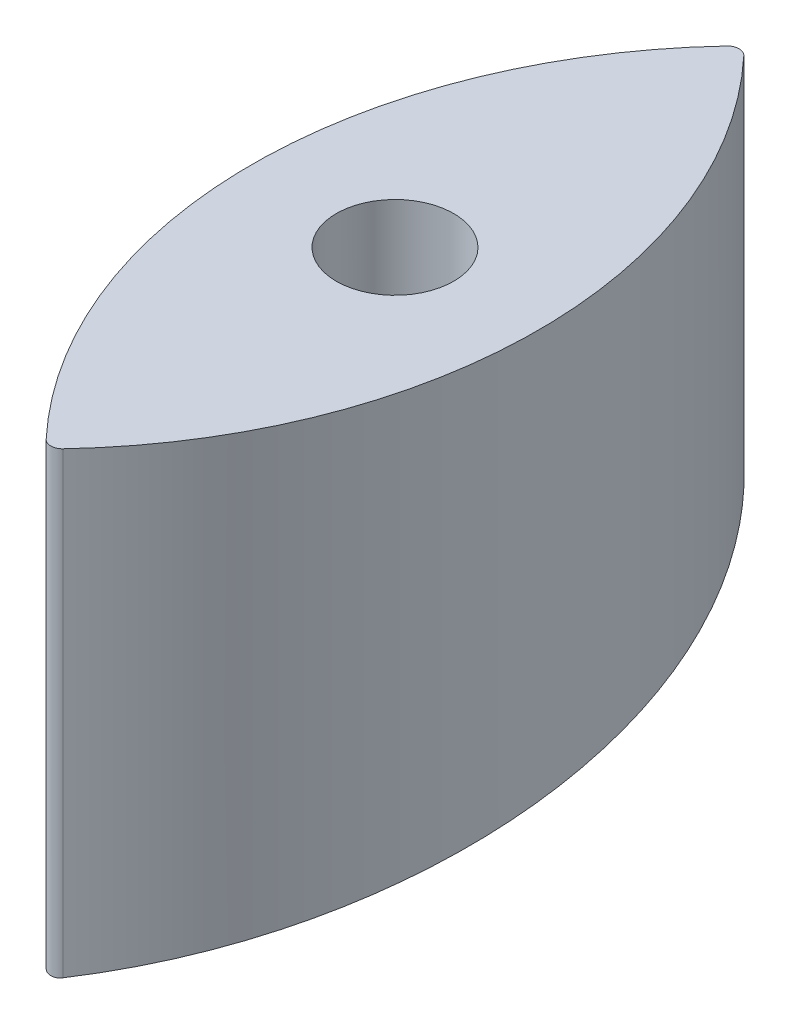
from build123d import *

# Parameters (mm, degrees)
BOSS_EXTRUDE1_DEPTH = 15.875
SKETCH3_R           = 6.5
CUT_EXTRUDE1_DEPTH  = 51.8000001


with BuildPart() as part:
    # Sketch2 → Boss-Extrude1 (new body, symmetric)
    with BuildSketch(Plane(origin=(0, 0, 0), x_dir=(0, 0, -1), z_dir=(1, 0, 0))):
        with BuildLine():
            Line((-38.1, -5.601130621), (-38.1, 45.198869379))
            Line((-38.1, 45.198869379), (38.1, 45.198869379))
            Line((38.1, 45.198869379), (38.1, 3.798196304))
            add(Edge.make_bspline(
                [(-38.1, -5.601130621), (-0.21894309, 0.874475249), (38.1, 3.798196304)],
                knots=[0, 0, 0, 1, 1, 1], degree=2))
        make_face()
    extrude(amount=BOSS_EXTRUDE1_DEPTH, both=True)

    # Sketch3 → Cut-Extrude1 (cut, through all)
    with BuildSketch(Plane(origin=(0, 45.198869379, 0), x_dir=(1, 0, 0), z_dir=(0, 1, 0))):
        with BuildLine():
            Line((0, -38.1), (15.875, -38.1))
            Line((15.875, -38.1), (15.875, -2.65e-07))
            ThreePointArc((15.875, -2.65e-07), (12.001057449, -20.2782212), (0.924852299, -37.700372463))
            ThreePointArc((0.924852299, -37.700372463), (0.503749428, -37.995820104), (0, -38.1))
        make_face()
        with BuildLine():
            ThreePointArc((0.924852299, 37.700372463), (12.001057547, 20.278220954), (15.875, -2.65e-07))
            Line((15.875, -2.65e-07), (15.875, 38.1))
            Line((15.875, 38.1), (0, 38.1))
            ThreePointArc((0, 38.1), (0.503749428, 37.995820104), (0.924852299, 37.700372463))
        make_face()
        with BuildLine():
            Line((-15.875, -38.1), (0, -38.1))
            ThreePointArc((0, -38.1), (-0.503749428, -37.995820104), (-0.924852299, -37.700372463))
            ThreePointArc((-0.924852299, -37.700372463), (-12.001057487, -20.278221106), (-15.875, -6.3e-08))
            Line((-15.875, -6.3e-08), (-15.875, -38.1))
        make_face()
        with BuildLine():
            ThreePointArc((-0.924852299, 37.700372463), (-0.503749428, 37.995820104), (0, 38.1))
            Line((0, 38.1), (-15.875, 38.1))
            Line((-15.875, 38.1), (-15.875, -6.3e-08))
            ThreePointArc((-15.875, -6.3e-08), (-12.00105751, 20.278221048), (-0.924852299, 37.700372463))
        make_face()
        Circle(SKETCH3_R)
    extrude(amount=-CUT_EXTRUDE1_DEPTH, mode=Mode.SUBTRACT)


solid = part.part
